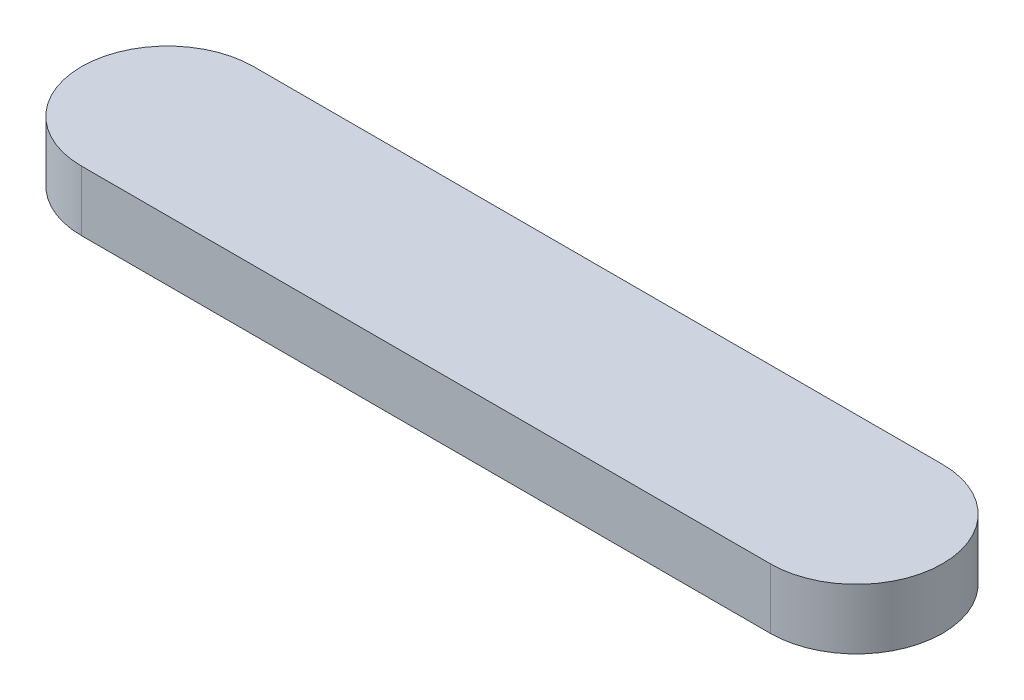
from build123d import *

# Parameters (mm, degrees)
BOSS_EXTRUDE1_DEPTH = 70
SKETCH3_R           = 10
BOSS_EXTRUDE2_DEPTH = 20
SKETCH4_R           = 10
BOSS_EXTRUDE3_DEPTH = 20


with BuildPart() as part:
    # Sketch2 → Boss-Extrude1 (new body)
    with BuildSketch(Plane(origin=(0, 0, 0), x_dir=(1, 0, 0), z_dir=(0, 1, 0))):
        with BuildLine():
            Line((0, 100), (800, 100))
            ThreePointArc((800, 100), (900, 0), (800, -100))
            Line((800, -100), (0, -100))
            ThreePointArc((0, -100), (-100, 0), (0, 100))
        make_face()
    extrude(amount=BOSS_EXTRUDE1_DEPTH)

    # Sketch3 → Boss-Extrude2 (add)
    with BuildSketch(Plane.XZ):
        Circle(SKETCH3_R)
    extrude(amount=BOSS_EXTRUDE2_DEPTH)

    # Sketch4 → Boss-Extrude3 (add)
    with BuildSketch(Plane.XZ):
        with Locations((800, 0)):
            Circle(SKETCH4_R)
    extrude(amount=BOSS_EXTRUDE3_DEPTH)


solid = part.part
